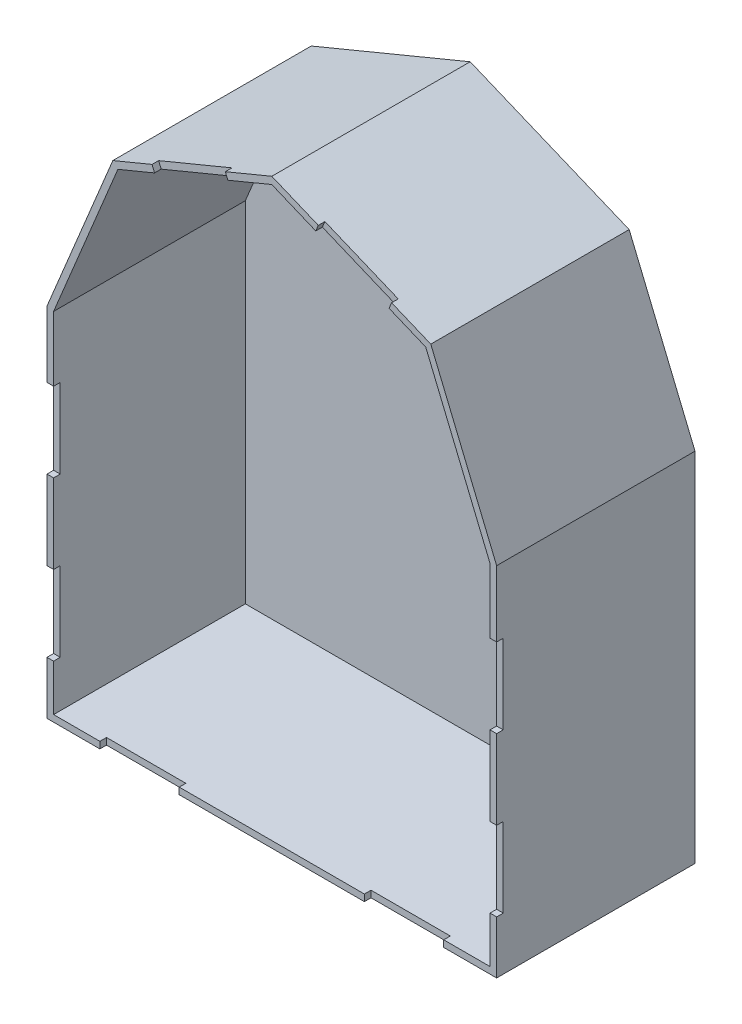
from build123d import *

# Parameters (mm, degrees)
BOSS_EXTRUDE1_DEPTH = 75
CUT_EXTRUDE1_DEPTH  = 72.5
SKETCH6_W           = 30
SKETCH6_H           = 2.5
SKETCH6_W_2         = 2.5
SKETCH6_H_2         = 30
CUT_EXTRUDE4_DEPTH  = 2.5
SKETCH8_R           = 5
CUT_EXTRUDE5_DEPTH  = 5


with BuildPart() as part:
    # Sketch1 → Boss-Extrude1 (new body)
    with BuildSketch(Plane.XY):
        Polygon((0, 0), (170, 0), (170, 135), (145.104076401, 195.104076401), (85, 220), (24.895923599, 195.104076401), (0, 135), align=None)
    extrude(amount=BOSS_EXTRUDE1_DEPTH)

    # Sketch2 → Cut-Extrude1 (cut)
    with BuildSketch(Plane.XY.offset(75)):
        Polygon((167.5, 134.502719082), (143.190659239, 193.190659239), (85, 217.294019499), (26.809340761, 193.190659239), (2.5, 134.502719082), (2.5, 2.5), (167.5, 2.5), align=None)
    extrude(amount=-CUT_EXTRUDE1_DEPTH, mode=Mode.SUBTRACT)

    # Sketch6 → Cut-Extrude4 (cut)
    with BuildSketch(Plane.XY.offset(75)):
        with Locations((135, 1.25)):
            Rectangle(SKETCH6_W, SKETCH6_H)
        with Locations((168.75, 35)):
            Rectangle(SKETCH6_W_2, SKETCH6_H_2)
        Polygon((101.616080276, 210.411413695), (129.332466251, 198.930910725), (130.289174832, 201.240609556), (102.572788857, 212.721112527), align=None)
        with Locations((168.75, 95)):
            Rectangle(SKETCH6_W_2, SKETCH6_H_2)
        Polygon((67.427211143, 212.721112527), (68.383919724, 210.411413695), (40.667533749, 198.930910725), (39.710825168, 201.240609556), align=None)
        with Locations((1.25, 95)):
            Rectangle(SKETCH6_W_2, SKETCH6_H_2)
        with Locations((1.25, 35)):
            Rectangle(SKETCH6_W_2, SKETCH6_H_2)
        with Locations((35, 1.25)):
            Rectangle(SKETCH6_W, SKETCH6_H)
    extrude(amount=-CUT_EXTRUDE4_DEPTH, mode=Mode.SUBTRACT)

    # Sketch8 → Cut-Extrude5 (cut)
    with BuildSketch(Plane(origin=(0, 2.5, 0), x_dir=(1, 0, 0), z_dir=(0, 1, 0))):
        with Locations((150, -40)):
            Circle(SKETCH8_R)
    extrude(amount=-CUT_EXTRUDE5_DEPTH, mode=Mode.SUBTRACT)


solid = part.part
